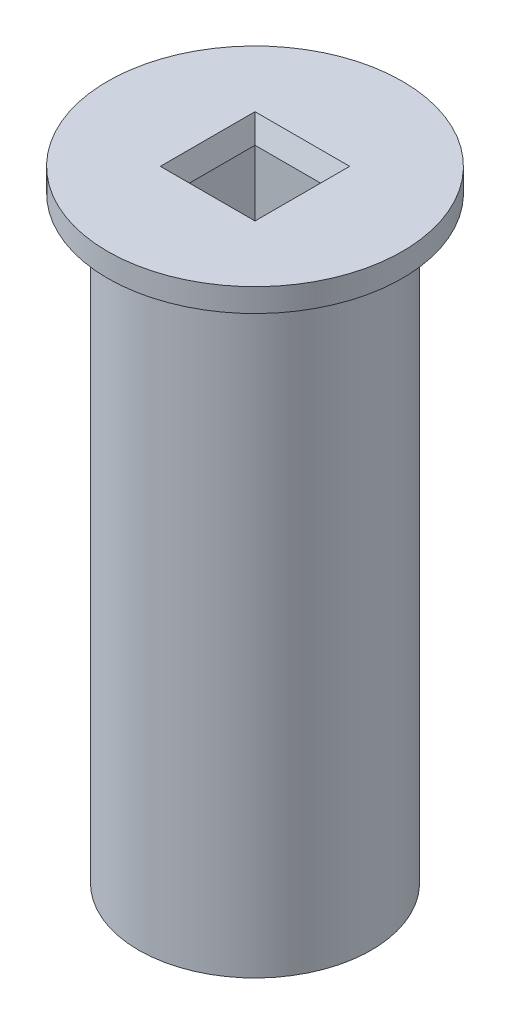
from build123d import *

# Parameters (mm, degrees)
SKETCH_1_R          = 15
SKETCH_1_W          = 10.2
SKETCH_1_H          = 10.2
EXTRUDE_1_DEPTH     = 80
SKETCH1_R           = 19
SKETCH1_W           = 10.2
SKETCH1_H           = 10.2
BOSS_EXTRUDE1_DEPTH = 3
CHAMFER1_SIZE       = 1
CHAMFER1_SIZE2      = 2.747477419


with BuildPart() as part:
    # Эскиз1 → Бобышка-Вытянуть1 (new body)
    with BuildSketch(Plane(origin=(0, 0, 0), x_dir=(1, 0, 0), z_dir=(0, 1, 0))):
        Circle(SKETCH_1_R)
        Rectangle(SKETCH_1_W, SKETCH_1_H, mode=Mode.SUBTRACT)
    extrude(amount=EXTRUDE_1_DEPTH)

    # Sketch1 → Boss-Extrude1 (add)
    with BuildSketch(Plane(origin=(0, 80, 0), x_dir=(1, 0, 0), z_dir=(0, 1, 0))):
        Circle(SKETCH1_R)
        Rectangle(SKETCH1_W, SKETCH1_H, mode=Mode.SUBTRACT)
    extrude(amount=-BOSS_EXTRUDE1_DEPTH)

    # Chamfer1
    chamfer1_edges = [part.edges().sort_by_distance(p)[0] for p in [
        (0, 80, -5.1),
        (-5.1, 80, 0),
        (0, 80, 5.1),
        (5.1, 80, 0),
    ]]
    chamfer1_side = [part.faces().sort_by_distance(p)[0] for p in [
        (-18.462598846, 80, 0),
    ]]
    chamfer(chamfer1_edges, length=CHAMFER1_SIZE, length2=CHAMFER1_SIZE2, reference=chamfer1_side[0])


solid = part.part
